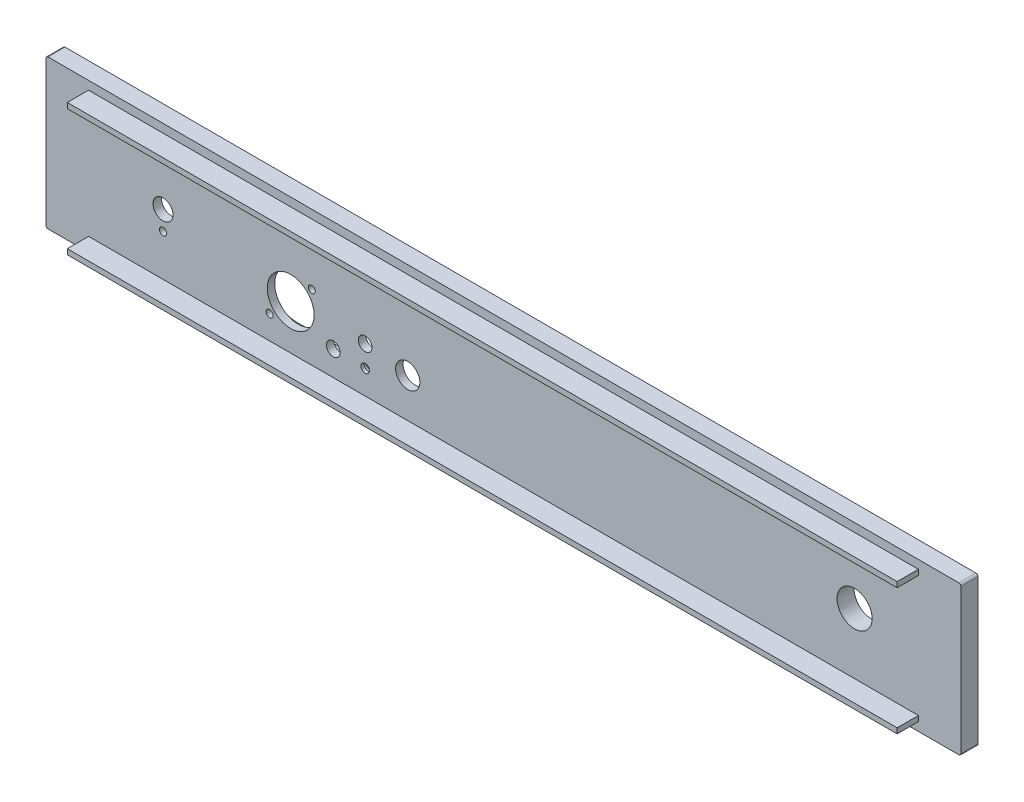
from build123d import *

# Parameters (mm, degrees)
SKETCH_1_W          = 430
SKETCH_1_H          = 70
EXTRUDE_1_DEPTH     = 8
FILLET_1_R          = 1
SKETCH_2_W          = 390
SKETCH_2_H          = 2.5
EXTRUDE_2_DEPTH     = 10
SKETCH_3_R          = 1.65
SKETCH_3_R_2        = 3.25
SKETCH_3_R_3        = 5.7
SKETCH_3_R_4        = 4.7
SKETCH_3_R_5        = 1.7
SKETCH_3_R_6        = 2
SKETCH_3_R_7        = 3.2
CUT_EXTRUDE_1_DEPTH = 19
CUT_EXTRUDE_2_DEPTH = 4.5
SKETCH_5_R          = 3.5
CUT_EXTRUDE_3_DEPTH = 2
SKETCH_6_R          = 8.25
CUT_EXTRUDE_4_DEPTH = 19
SKETCH_7_R          = 20
CUT_EXTRUDE_5_DEPTH = 4


with BuildPart() as part:
    # 草圖1 → 填料-伸長1 (new body)
    with BuildSketch(Plane.XY):
        Rectangle(SKETCH_1_W, SKETCH_1_H)
    extrude(amount=EXTRUDE_1_DEPTH)

    # 圓角1
    fillet_1_edges = [part.edges().sort_by_distance(p)[0] for p in [
        (215, -35, 4),
        (-215, -35, 4),
        (-215, 35, 4),
        (215, 35, 4),
    ]]
    fillet(fillet_1_edges, radius=FILLET_1_R)

    # 草圖2 → 填料-伸長2 (add)
    with BuildSketch(Plane.XY.offset(8)):
        with Locations((0, 29.75)):
            Rectangle(SKETCH_2_W, SKETCH_2_H)
        with Locations((0, -29.75)):
            Rectangle(SKETCH_2_W, SKETCH_2_H)
    extrude(amount=EXTRUDE_2_DEPTH)

    # 草圖3 → 除料-伸長1 (cut, through all)
    with BuildSketch(Plane(origin=(0, 0, 0), x_dir=(-1, 0, 0), z_dir=(0, 0, -1))):
        with Locations((90.1, 2.4)):
            Circle(SKETCH_3_R)
        with BuildLine():
            ThreePointArc((111, -7.5), (110.23508972, -3.469747103), (108.04673847, 0))
            Line((108.04673847, 0), (91.95326153, 0))
            ThreePointArc((91.95326153, 0), (95.969747103, -17.73508972), (111, -7.5))
        make_face()
        with BuildLine():
            Line((91.95326153, 0), (108.04673847, 0))
            ThreePointArc((108.04673847, 0), (100, 3.5), (91.95326153, 0))
        make_face()
        with Locations((109.9, -17.4)):
            Circle(SKETCH_3_R)
        with Locations((80, -16.75)):
            Circle(SKETCH_3_R_2)
        with Locations((45, -10.11)):
            Circle(SKETCH_3_R_3)
        with Locations((160, 0)):
            Circle(SKETCH_3_R_4)
        with Locations((160, -9)):
            Circle(SKETCH_3_R_5)
        with BuildLine():
            ThreePointArc((155.3, 0), (160, -4.7), (164.7, 0))
            Line((164.7, 0), (155.3, 0))
        make_face()
        with BuildLine():
            Line((155.3, 0), (164.7, 0))
            ThreePointArc((164.7, 0), (160, 4.7), (155.3, 0))
        make_face()
        with Locations((65, -17.2)):
            Circle(SKETCH_3_R_6)
        with Locations((65, -7.2)):
            Circle(SKETCH_3_R_7)
    extrude(amount=-CUT_EXTRUDE_1_DEPTH, mode=Mode.SUBTRACT)

    # 草圖4 → 除料-伸長2 (cut)
    with BuildSketch(Plane(origin=(0, 0, 0), x_dir=(-1, 0, 0), z_dir=(0, 0, -1))):
        with BuildLine():
            Line((45, 7.5), (105, 7.5))
            ThreePointArc((105, 7.5), (120, -7.5), (105, -22.5))
            Line((105, -22.5), (45, -22.5))
            ThreePointArc((45, -22.5), (30, -7.5), (45, 7.5))
        make_face()
    extrude(amount=-CUT_EXTRUDE_2_DEPTH, mode=Mode.SUBTRACT)

    # 草圖5 → 除料-伸長3 (cut)
    with BuildSketch(Plane(origin=(0, 0, 4.5), x_dir=(-1, 0, 0), z_dir=(0, 0, -1))):
        with Locations((65, -17.2)):
            Circle(SKETCH_5_R)
    extrude(amount=-CUT_EXTRUDE_3_DEPTH, mode=Mode.SUBTRACT)

    # 草圖6 → 除料-伸長4 (cut, through all)
    with BuildSketch(Plane(origin=(0, 0, 0), x_dir=(-1, 0, 0), z_dir=(0, 0, -1))):
        with Locations((-165, 0)):
            Circle(SKETCH_6_R)
    extrude(amount=-CUT_EXTRUDE_4_DEPTH, mode=Mode.SUBTRACT)

    # 草圖7 → 除料-伸長5 (cut)
    with BuildSketch(Plane(origin=(0, 0, 0), x_dir=(-1, 0, 0), z_dir=(0, 0, -1))):
        with Locations((160, 0.609446204)):
            Circle(SKETCH_7_R)
    extrude(amount=-CUT_EXTRUDE_5_DEPTH, mode=Mode.SUBTRACT)


solid = part.part
